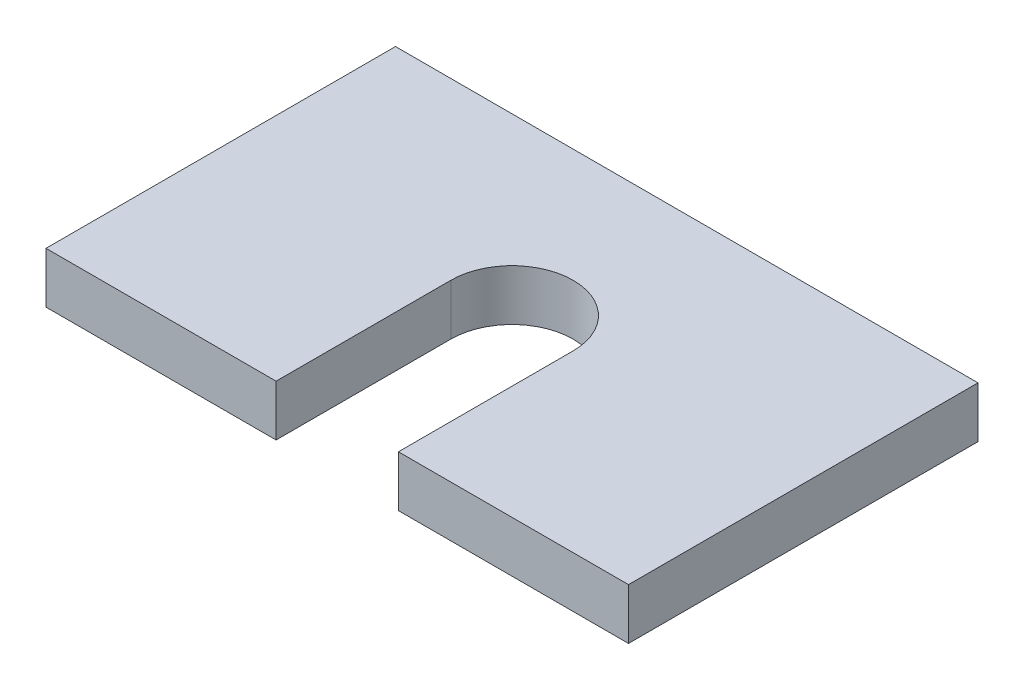
from build123d import *

# Parameters (mm, degrees)
BOSS_EXTRUDE1_DEPTH = 11.1125


with BuildPart() as part:
    # Sketch1 → Boss-Extrude1 (new body)
    with BuildSketch(Plane(origin=(0, 0, 0), x_dir=(1, 0, 0), z_dir=(0, 1, 0))):
        with BuildLine():
            Line((-13.335, -38.1), (-13.335, 0))
            ThreePointArc((-13.335, 0), (0, 13.335), (13.335, 0))
            Line((13.335, 0), (13.335, -38.1))
            Line((13.335, -38.1), (63.5, -38.1))
            Line((63.5, -38.1), (63.5, 38.1))
            Line((63.5, 38.1), (-63.5, 38.1))
            Line((-63.5, 38.1), (-63.5, -38.1))
            Line((-63.5, -38.1), (-13.335, -38.1))
        make_face()
    extrude(amount=BOSS_EXTRUDE1_DEPTH)


solid = part.part
